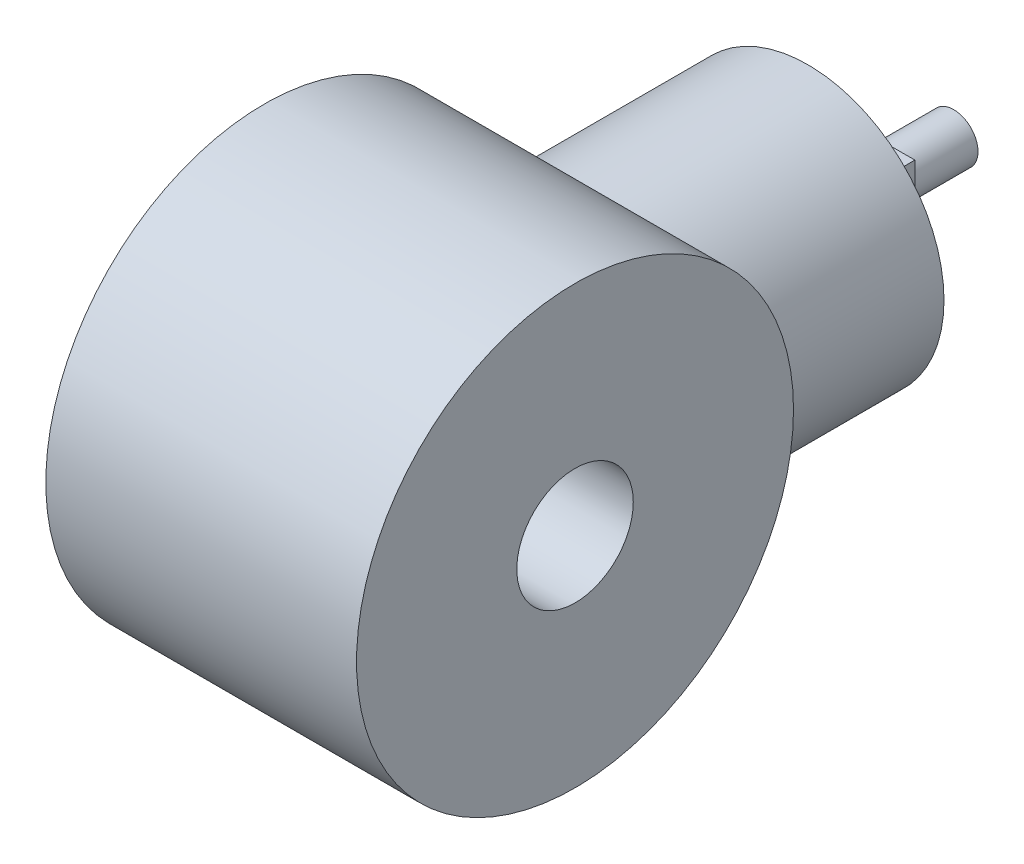
from build123d import *
from build123d.topology import SkipClean

# Parameters (mm, degrees)
SKETCH2_R           = 6
BOSS_EXTRUDE1_DEPTH = 16
SKETCH3_R           = 14
BOSS_EXTRUDE2_DEPTH = 40
SKETCH4_R           = 6
CUT_EXTRUDE1_DEPTH  = 56.948637328
SKETCH5_W           = 28
SKETCH5_H           = 30
BOSS_EXTRUDE3_DEPTH = 2.5
SKETCH8_R           = 15.28865651
SKETCH8_R_2         = 14
CUT_EXTRUDE2_DEPTH  = 35
SKETCH9_R           = 3
CUT_EXTRUDE3_DEPTH  = 35
CUT_EXTRUDE4_DEPTH  = 81.18883969
SKETCH11_W          = 30
SKETCH11_H          = 5
CUT_EXTRUDE5_DEPTH  = 15
SKETCH14_R          = 2.5
BOSS_EXTRUDE4_DEPTH = 15
SKETCH17_W          = 12
SKETCH17_H          = 12
BOSS_EXTRUDE6_DEPTH = 5


with BuildPart() as part:
    # Sketch2 → Boss-Extrude1 (new, symmetric)
    with BuildSketch(Plane(origin=(0, 0, 0), x_dir=(0, 0, -1), z_dir=(1, 0, 0))):
        with BuildLine():
            Line((-25, -17.5), (-4.873971328, -21.965755245))
            ThreePointArc((-4.873971328, -21.965755245), (22.5, 0), (-4.873971328, 21.965755245))
            Line((-4.873971328, 21.965755245), (-25, 17.5))
            Line((-25, 17.5), (-25, -17.5))
        make_face()
        Circle(SKETCH2_R, mode=Mode.SUBTRACT)
    extrude(amount=BOSS_EXTRUDE1_DEPTH, both=True)

    # Sketch3 → Boss-Extrude2 (add)
    with BuildSketch(Plane.XY):
        Circle(SKETCH3_R)
    extrude(amount=-BOSS_EXTRUDE2_DEPTH)

    # Sketch4 → Cut-Extrude1 (cut, through all)
    with BuildSketch(Plane(origin=(16, 0, 0), x_dir=(0, 0, -1), z_dir=(1, 0, 0))):
        Circle(SKETCH4_R)
    extrude(amount=-CUT_EXTRUDE1_DEPTH, mode=Mode.SUBTRACT)

    # Sketch5 → Boss-Extrude3 (add, symmetric)
    with BuildSketch(Plane(origin=(0, 0, 0), x_dir=(1, 0, 0), z_dir=(0, 1, 0))):
        with Locations((0, 55)):
            Rectangle(SKETCH5_W, SKETCH5_H)
    extrude(amount=BOSS_EXTRUDE3_DEPTH, both=True)

    # Sketch8 → Cut-Extrude2 (cut)
    with BuildSketch(Plane(origin=(0, 0, -70), x_dir=(-1, 0, 0), z_dir=(0, 0, -1))):
        Circle(SKETCH8_R)
        with Locations(Location((0, 0, 0), (0, 0, 180))):
            Circle(SKETCH8_R_2, mode=Mode.SUBTRACT)
    extrude(amount=-CUT_EXTRUDE2_DEPTH, mode=Mode.SUBTRACT)

    # Sketch9 → Cut-Extrude3 (cut)
    with BuildSketch(Plane(origin=(0, 2.5, 0), x_dir=(1, 0, 0), z_dir=(0, 1, 0))):
        with Locations(Location((-9, 62, 0), (0, 0, 270))):
            Circle(SKETCH9_R)
        with Locations(Location((9, 62, 0), (0, 0, 270))):
            Circle(SKETCH9_R)
    extrude(amount=-CUT_EXTRUDE3_DEPTH, mode=Mode.SUBTRACT)

    # Sketch10 → Cut-Extrude4 (cut, through all)
    with SkipClean():  # the faces are left unmerged after this step: merging them gives an invalid solid
        with BuildSketch(Plane(origin=(16, 0, 0), x_dir=(0, 0, -1), z_dir=(1, 0, 0))):
            with BuildLine():
                Line((-25, -17.5), (-4.873971328, -21.965755245))
                ThreePointArc((-4.873971328, -21.965755245), (-22.5, 0), (-4.873971328, 21.965755245))
                Line((-4.873971328, 21.965755245), (-25, 17.5))
                Line((-25, 17.5), (-25, -17.5))
            make_face()
        extrude(amount=-CUT_EXTRUDE4_DEPTH, mode=Mode.SUBTRACT)

    # Sketch11 → Cut-Extrude5 (cut, symmetric)
    with SkipClean():  # the faces are left unmerged after this step: merging them gives an invalid solid
        with BuildSketch(Plane(origin=(0, 0, 0), x_dir=(0, 0, -1), z_dir=(1, 0, 0))):
            with Locations((55, 0)):
                Rectangle(SKETCH11_W, SKETCH11_H)
        extrude(amount=CUT_EXTRUDE5_DEPTH, both=True, mode=Mode.SUBTRACT)

    # Sketch14 → Boss-Extrude4 (add)
    with SkipClean():  # the faces are left unmerged after this step: merging them gives an invalid solid
        with BuildSketch(Plane(origin=(0, 0, -40), x_dir=(-1, 0, 0), z_dir=(0, 0, -1))):
            Circle(SKETCH14_R)
        extrude(amount=BOSS_EXTRUDE4_DEPTH)

    # Sketch17 → Boss-Extrude6 (add)
    with SkipClean():  # the faces are left unmerged after this step: merging them gives an invalid solid
        with BuildSketch(Plane(origin=(0, 0, -40), x_dir=(-1, 0, 0), z_dir=(0, 0, -1))):
            Rectangle(SKETCH17_W, SKETCH17_H)
        extrude(amount=BOSS_EXTRUDE6_DEPTH)


solid = part.part
